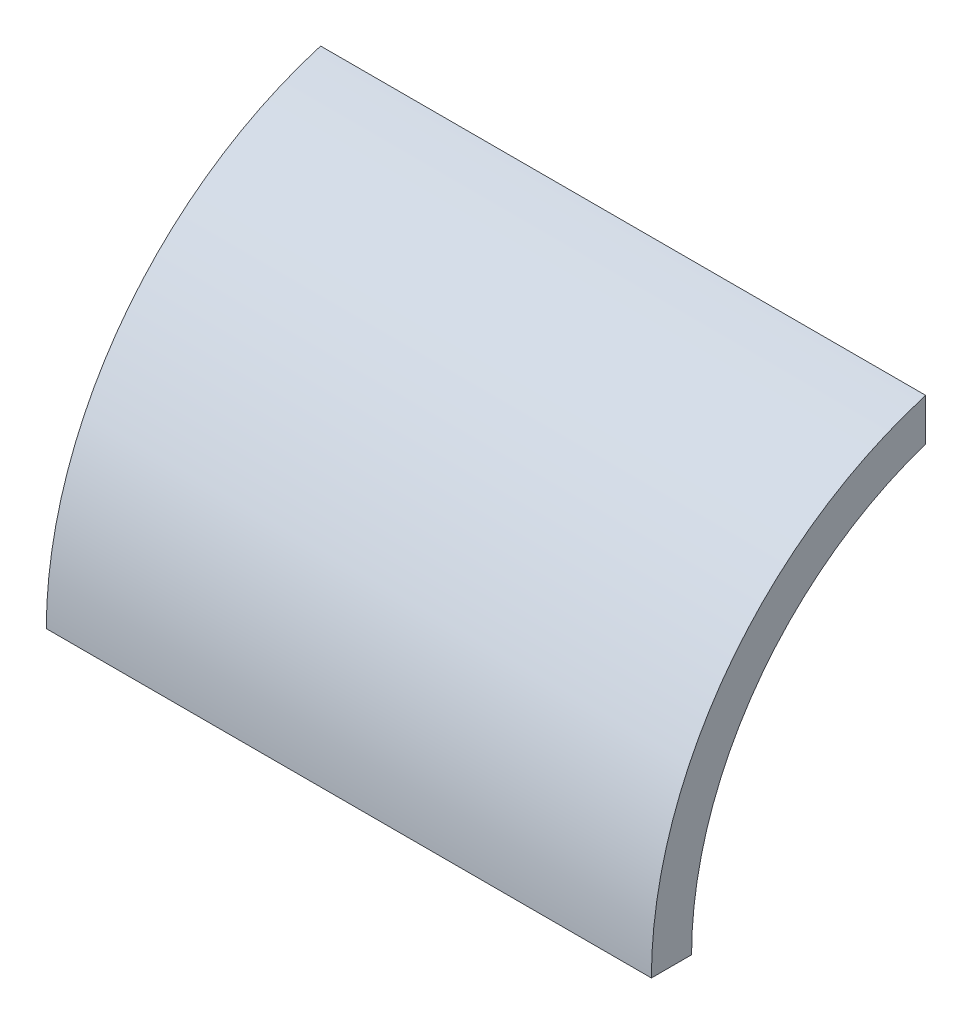
from build123d import *

# Parameters (mm, degrees)
BOSS_EXTRUDE1_DEPTH = 101.6


with BuildPart() as part:
    # Sketch1 → Boss-Extrude1 (new body)
    with BuildSketch(Plane(origin=(0, 0, 0), x_dir=(0, 0, -1), z_dir=(1, 0, 0))):
        with BuildLine():
            Line((-57.6072, 0), (-64.354075, 0))
            ThreePointArc((-64.354075, 0), (-51.569735159, 38.496875), (-18.296093908, 61.698459598))
            Line((-18.296093908, 61.698459598), (-18.296093908, 54.624558941))
            ThreePointArc((-18.296093908, 54.624558941), (-46.757759959, 33.649686112), (-57.6072, 0))
        make_face()
    extrude(amount=BOSS_EXTRUDE1_DEPTH)


solid = part.part
